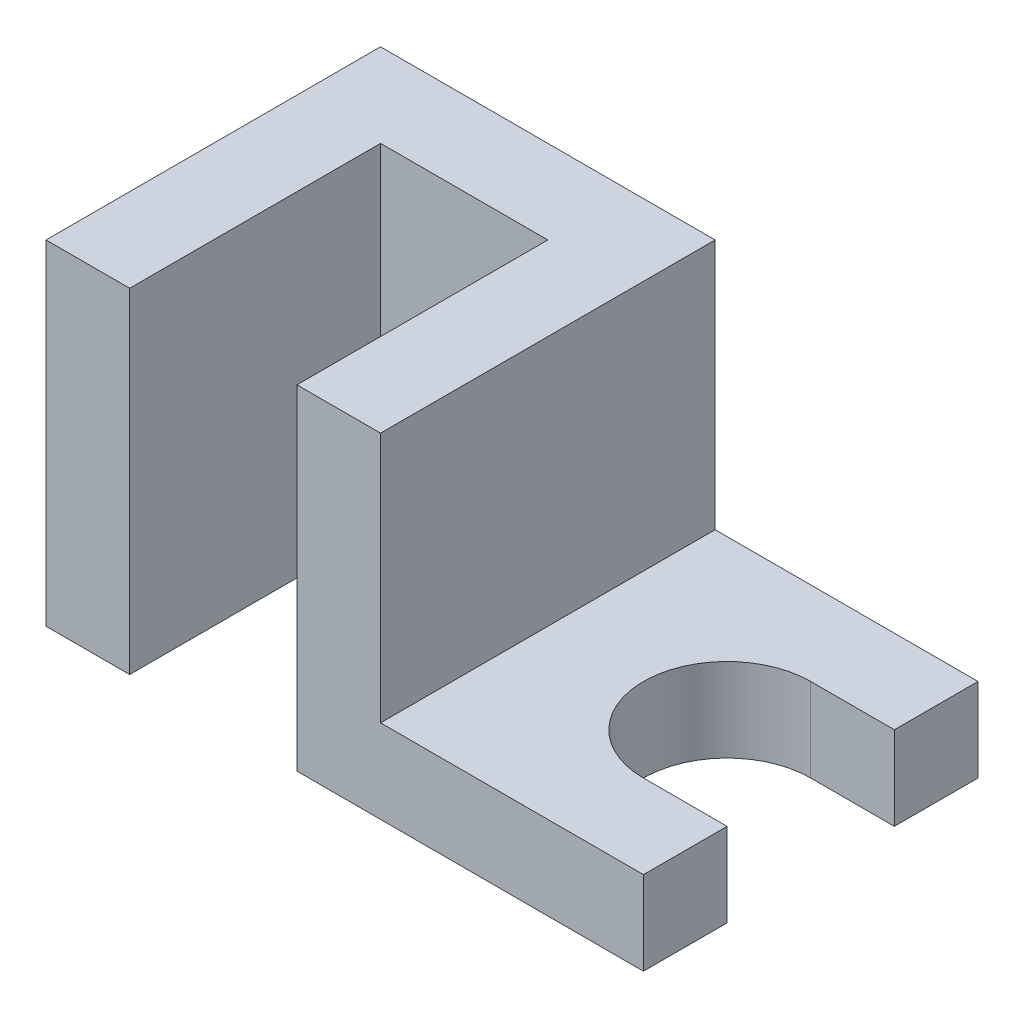
from build123d import *

# Parameters (mm, degrees)
BOSS_EXTRUDE1_DEPTH = 7
BOSS_EXTRUDE2_DEPTH = 28


with BuildPart() as part:
    # Sketch1 → Boss-Extrude1 (new body)
    with BuildSketch(Plane(origin=(0, 0, 0), x_dir=(1, 0, 0), z_dir=(0, 1, 0))):
        with BuildLine():
            Line((50, 28), (28, 28))
            Line((28, 28), (28, 0))
            Line((28, 0), (50, 0))
            Line((50, 0), (50, 7))
            Line((50, 7), (43, 7))
            ThreePointArc((43, 7), (36, 14), (43, 21))
            Line((43, 21), (50, 21))
            Line((50, 21), (50, 28))
        make_face()
    extrude(amount=BOSS_EXTRUDE1_DEPTH)

    # Sketch1_3 → Boss-Extrude2 (add)
    with BuildSketch(Plane(origin=(0, 0, 0), x_dir=(1, 0, 0), z_dir=(0, 1, 0))):
        Polygon((0, 28), (0, 0), (7, 0), (7, 21), (21, 21), (21, 0), (28, 0), (28, 28), align=None)
    extrude(amount=BOSS_EXTRUDE2_DEPTH)


solid = part.part
